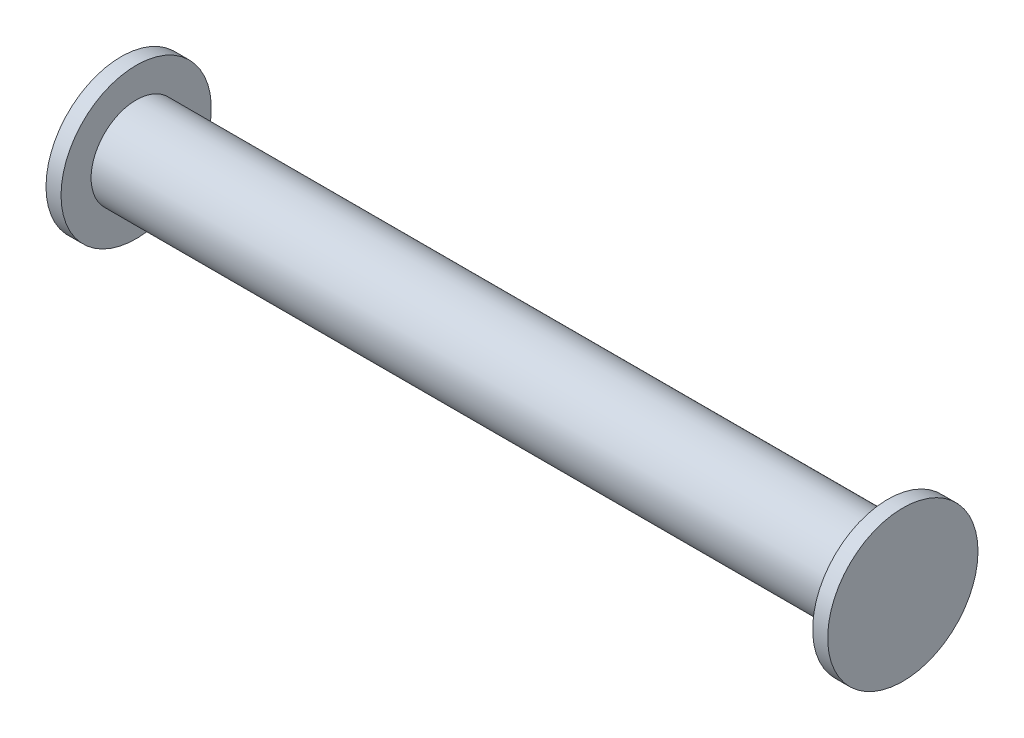
from build123d import *

# Parameters (mm, degrees)
SKETCH1_R           = 6
SKETCH1_R_2         = 5
BOSS_EXTRUDE1_DEPTH = 50
SKETCH2_R           = 10
BOSS_EXTRUDE4_DEPTH = 2
SKETCH5_R           = 10
BOSS_EXTRUDE5_DEPTH = 2


with BuildPart() as part:
    # Sketch1 → Boss-Extrude1 (new body, symmetric)
    with BuildSketch(Plane(origin=(0, 0, 0), x_dir=(0, 0, -1), z_dir=(1, 0, 0))):
        Circle(SKETCH1_R)
        Circle(SKETCH1_R_2, mode=Mode.SUBTRACT)
    extrude(amount=BOSS_EXTRUDE1_DEPTH, both=True)


with BuildPart() as body_2:
    # Sketch2 → Boss-Extrude4 (new body)
    with BuildSketch(Plane.ZY.offset(50)):
        Circle(SKETCH2_R)
    extrude(amount=BOSS_EXTRUDE4_DEPTH)


with BuildPart() as body_3:
    # Sketch5 → Boss-Extrude5 (new body)
    with BuildSketch(Plane(origin=(50, 0, 0), x_dir=(0, 0, -1), z_dir=(1, 0, 0))):
        Circle(SKETCH5_R)
    extrude(amount=BOSS_EXTRUDE5_DEPTH)


solid = Compound([part.part, body_2.part, body_3.part])
